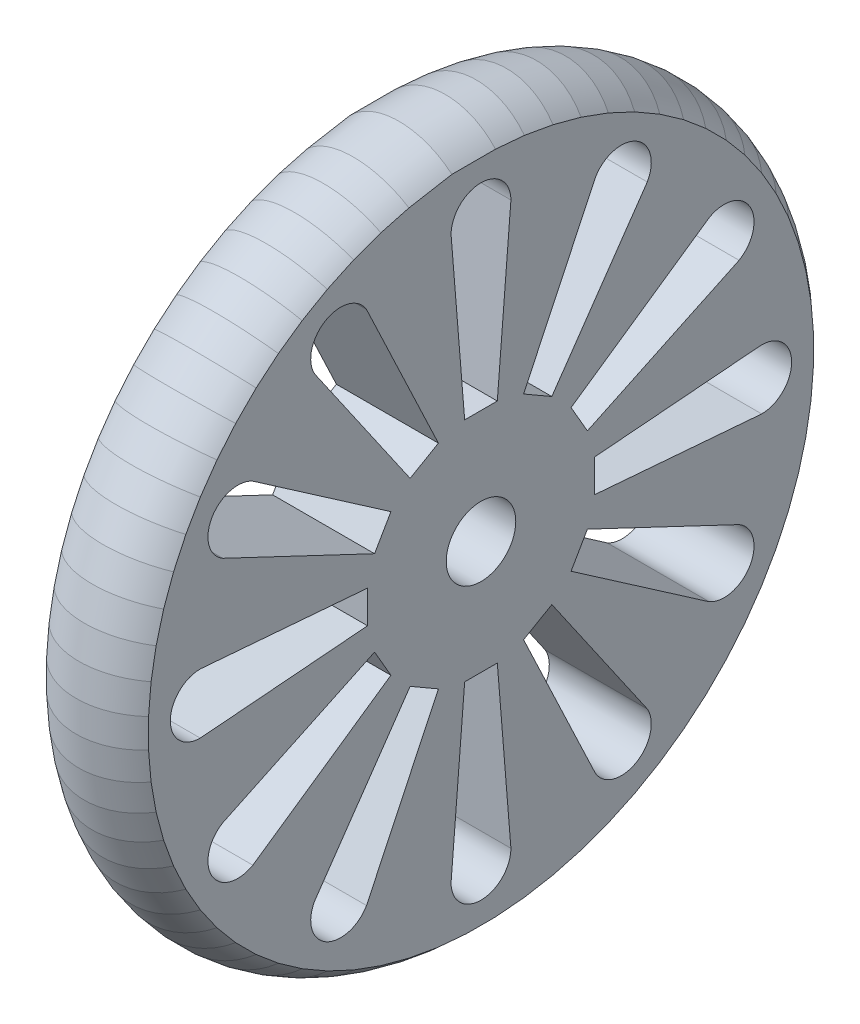
from build123d import *

# Parameters (mm, degrees)
SKETCH1_R           = 20
SKETCH1_R_2         = 1.705
BOSS_EXTRUDE1_DEPTH = 5
CUT_EXTRUDE1_DEPTH  = 8
CIRPATTERN1_COUNT   = 12
CUT_EXTRUDE2_DEPTH  = 2.5
CIRPATTERN2_COUNT   = 71
CIRPATTERN2_ANGLE   = 350


with BuildPart() as part:
    # Sketch1 → Boss-Extrude1 (new body)
    with BuildSketch(Plane(origin=(0, 0, 0), x_dir=(0, 0, -1), z_dir=(1, 0, 0))):
        Circle(SKETCH1_R)
        Circle(SKETCH1_R_2, mode=Mode.SUBTRACT)
    extrude(amount=BOSS_EXTRUDE1_DEPTH)

    # Sketch2 → Cut-Extrude1 (cut)
    with BuildSketch(Plane(origin=(0, 0, 0), x_dir=(0, 0, -1), z_dir=(1, 0, 0))):
        with BuildLine():
            Line((1.467292325, 13.76439168), (0.800439906, 5.562312437))
            Line((0.800439906, 5.562312437), (-0.800439906, 5.562312437))
            Line((-0.800439906, 5.562312437), (-1.467292325, 13.76439168))
            ThreePointArc((-1.467292325, 13.76439168), (0, 15.231684005), (1.467292325, 13.76439168))
        make_face()
    cut_extrude1 = extrude(amount=CUT_EXTRUDE1_DEPTH, mode=Mode.SUBTRACT)

    # CirPattern1: Cut-Extrude1 ×12 about axis
    cirpattern1_axis = Axis((0, 0, 0), (1, 0, 0))
    for i in range(1, CIRPATTERN1_COUNT):
        add(cut_extrude1.rotate(cirpattern1_axis, i * 360 / CIRPATTERN1_COUNT), mode=Mode.SUBTRACT)

    # Sketch6 → Cut-Extrude2 (cut, symmetric)
    with BuildSketch(Plane.XY):
        with BuildLine():
            Line((0, 16.3), (0, 20))
            Line((0, 20), (5, 20))
            Line((5, 20), (5, 16.3))
            ThreePointArc((5, 16.3), (2.5, 17.350510257), (0, 16.3))
        make_face()
    cut_extrude2 = extrude(amount=CUT_EXTRUDE2_DEPTH, both=True, mode=Mode.SUBTRACT)

    # CirPattern2: Cut-Extrude2 ×71 about axis
    cirpattern2_axis = Axis((5, 0, 0), (-1, 0, 0))
    for i in range(1, CIRPATTERN2_COUNT):
        add(cut_extrude2.rotate(cirpattern2_axis, i * CIRPATTERN2_ANGLE / (CIRPATTERN2_COUNT - 1)), mode=Mode.SUBTRACT)


solid = part.part
